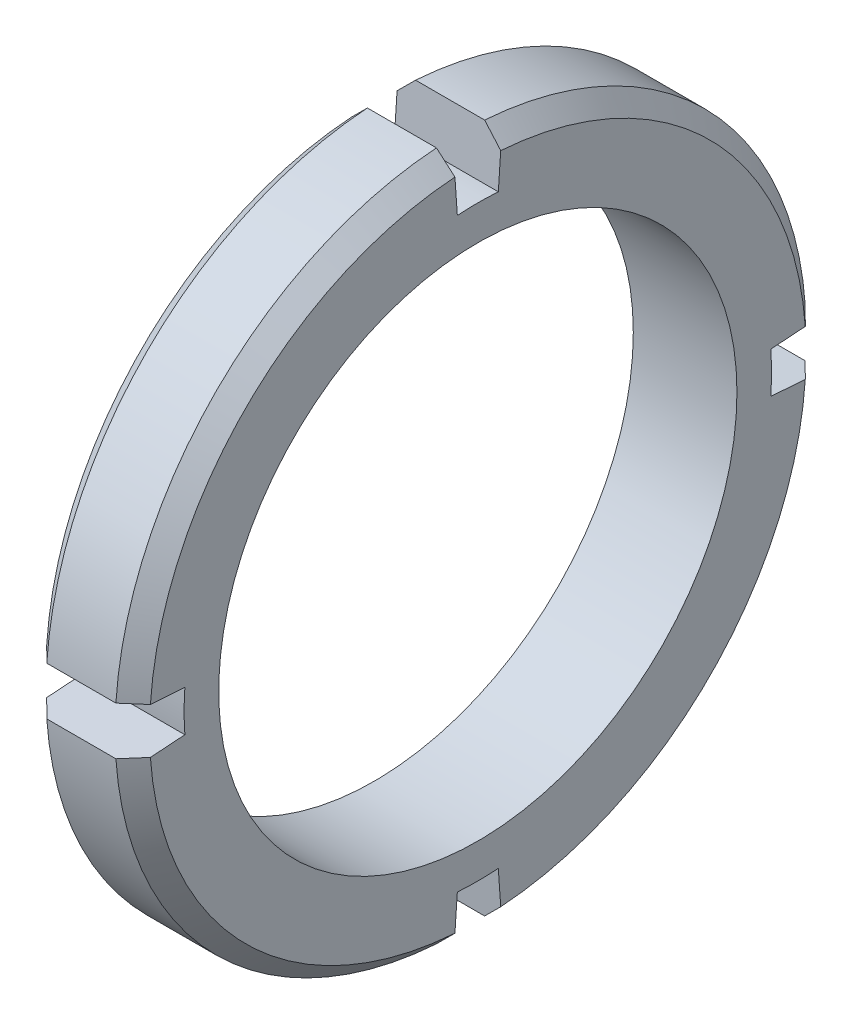
from build123d import *

# Parameters (mm, degrees)
SKETCH_1_R               = 20
SKETCH_1_R_2             = 15
EXTRUDE_1_DEPTH          = 6
CHAMFER_1_SIZE           = 1
CUT_EXTRUDE_1_DEPTH      = 10
PATTERN_CIRCULAR_1_COUNT = 4


with BuildPart() as part:
    # 草图1 → 凸台-拉伸1 (new body)
    with BuildSketch(Plane(origin=(0, 0, 0), x_dir=(0, 0, -1), z_dir=(1, 0, 0))):
        Circle(SKETCH_1_R)
        Circle(SKETCH_1_R_2, mode=Mode.SUBTRACT)
    extrude(amount=EXTRUDE_1_DEPTH)

    # 倒角1
    chamfer_1_edges = [part.edges().sort_by_distance(p)[0] for p in [
        (6, 0, 20),
        (0, 0, 20),
    ]]
    chamfer(chamfer_1_edges, length=CHAMFER_1_SIZE)

    # 草图2 → 切除-拉伸1 (cut)
    with BuildSketch(Plane(origin=(6, 0, 0), x_dir=(0, 0, -1), z_dir=(1, 0, 0))):
        with BuildLine():
            Line((16.958588854, -1.185860054), (20.747478718, -1.450805043))
            ThreePointArc((20.747478718, -1.450805043), (20.798141947, 0), (20.747478718, 1.450805043))
            Line((20.747478718, 1.450805043), (16.958588854, 1.185860054))
            ThreePointArc((16.958588854, 1.185860054), (17, 0), (16.958588854, -1.185860054))
        make_face()
    cut_extrude_1 = extrude(amount=-CUT_EXTRUDE_1_DEPTH, mode=Mode.SUBTRACT)

    # 阵列(圆周)1: 切除-拉伸1 ×4 about axis
    pattern_circular_1_axis = Axis((6, 0, 0), (1, 0, 0))
    for i in range(1, PATTERN_CIRCULAR_1_COUNT):
        add(cut_extrude_1.rotate(pattern_circular_1_axis, i * 360 / PATTERN_CIRCULAR_1_COUNT), mode=Mode.SUBTRACT)


solid = part.part
